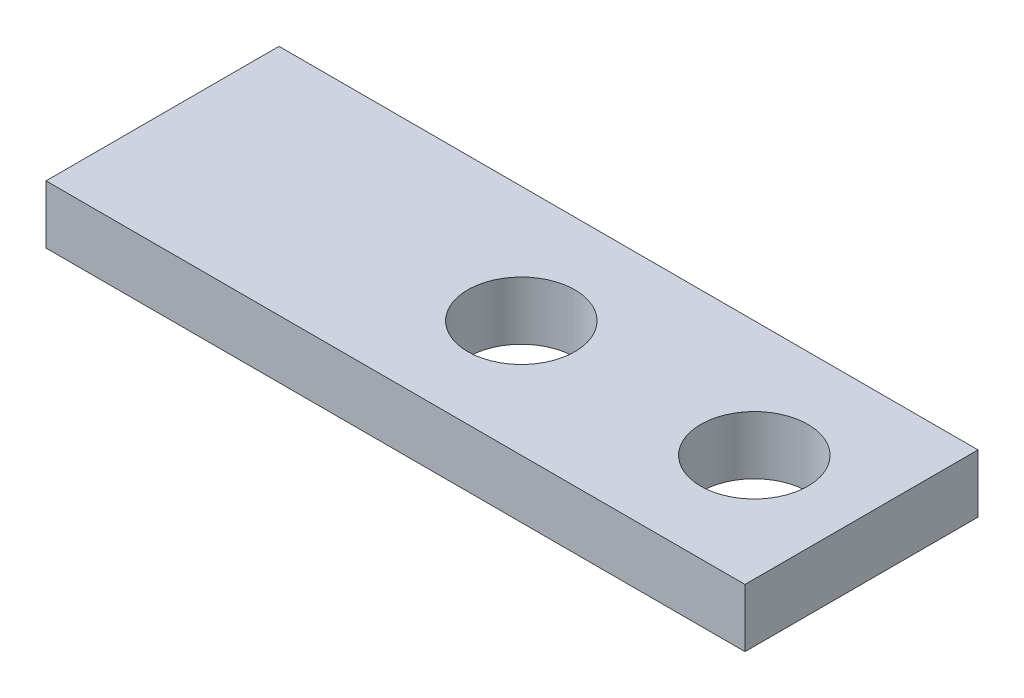
from build123d import *

# Parameters (mm, degrees)
SKETCH1_W           = 76.2
SKETCH1_H           = 25.4
SKETCH1_R           = 5.842
BOSS_EXTRUDE1_DEPTH = 6.35


with BuildPart() as part:
    # Sketch1 → Boss-Extrude1 (new body)
    with BuildSketch(Plane(origin=(0, 0, 0), x_dir=(1, 0, 0), z_dir=(0, 1, 0))):
        Rectangle(SKETCH1_W, SKETCH1_H)
        with Locations((26.416, 0)):
            Circle(SKETCH1_R, mode=Mode.SUBTRACT)
        with Locations((1.016, 0)):
            Circle(SKETCH1_R, mode=Mode.SUBTRACT)
    extrude(amount=BOSS_EXTRUDE1_DEPTH)


solid = part.part
